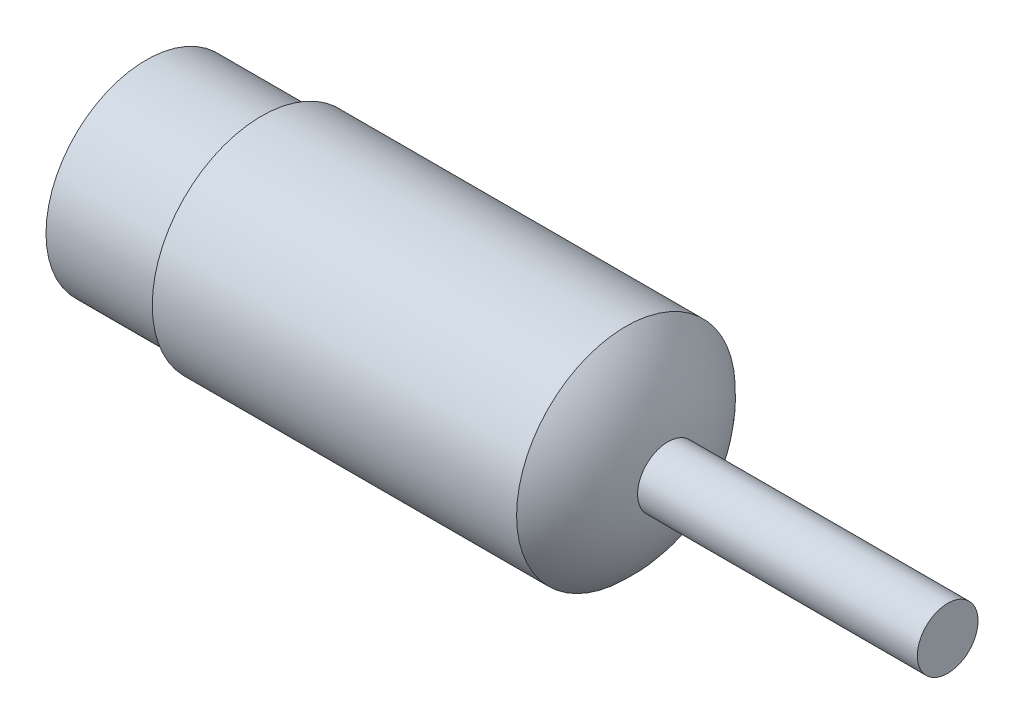
from build123d import *

# Parameters (mm, degrees)
SKETCH2_R           = 2.5
BOSS_EXTRUDE1_DEPTH = 66


with BuildPart() as part:
    # Sketch1 → Revolve1 (revolve)
    with BuildSketch(Plane.XY):
        with BuildLine():
            Line((0, 0), (0, 8.25))
            Line((0, 8.25), (9.5, 8.25))
            Line((9.5, 8.25), (9.5, 9))
            Line((9.5, 9), (39.5, 9))
            ThreePointArc((39.5, 9), (42.338390167, 4.923262843), (43, 0))
            Line((43, 0), (0, 0))
        make_face()
    revolve(axis=Axis((0, 0, 0), (1, 0, 0)))

    # Sketch2 → Boss-Extrude1 (add)
    with BuildSketch(Plane.ZY):
        Circle(SKETCH2_R)
    extrude(amount=-BOSS_EXTRUDE1_DEPTH)


solid = part.part
